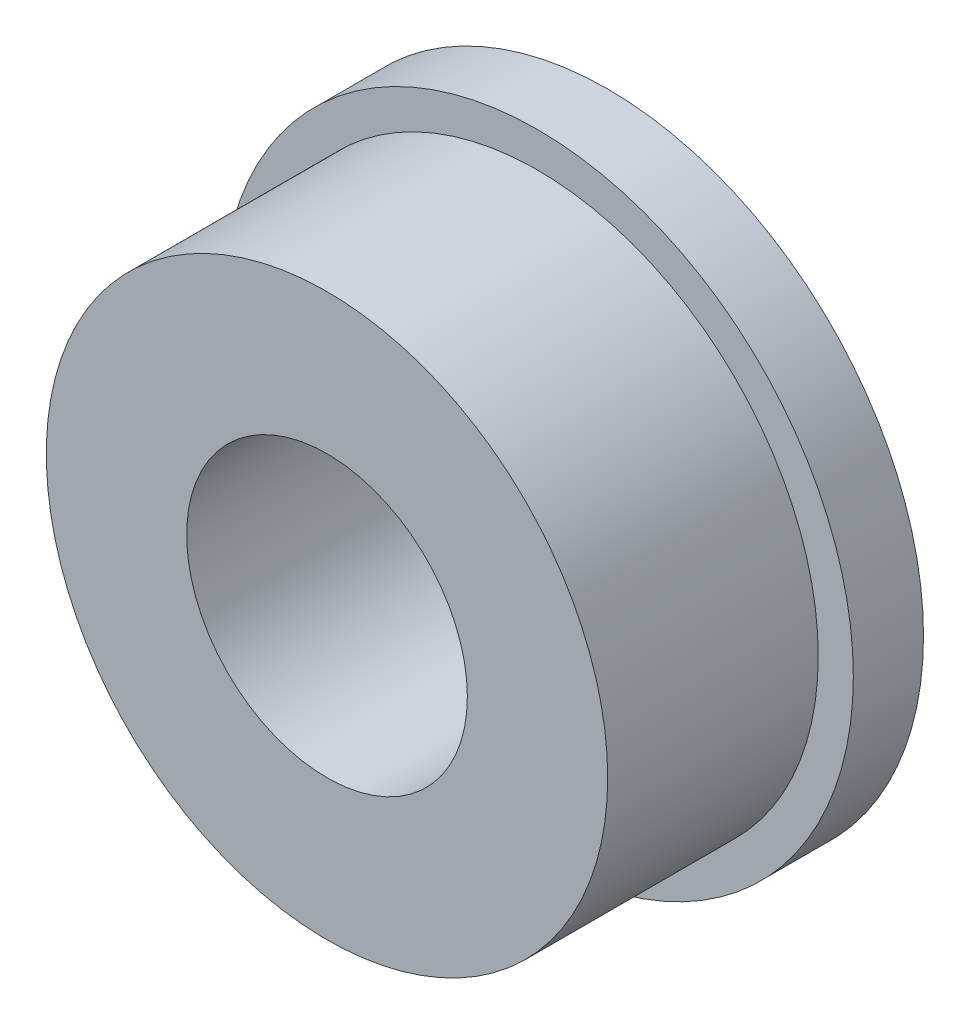
from build123d import *

# Parameters (mm, degrees)
SKETCH_1_R      = 9
SKETCH_1_R_2    = 4
EXTRUDE_1_DEPTH = 2
SKETCH_2_R      = 8
SKETCH_2_R_2    = 4
EXTRUDE_2_DEPTH = 6


with BuildPart() as part:
    # 草图1 → 凸台-拉伸1 (new body)
    with BuildSketch(Plane.XY):
        Circle(SKETCH_1_R)
        Circle(SKETCH_1_R_2, mode=Mode.SUBTRACT)
    extrude(amount=EXTRUDE_1_DEPTH)

    # 草图2 → 凸台-拉伸2 (add)
    with BuildSketch(Plane.XY.offset(2)):
        Circle(SKETCH_2_R)
        Circle(SKETCH_2_R_2, mode=Mode.SUBTRACT)
    extrude(amount=EXTRUDE_2_DEPTH)


solid = part.part
